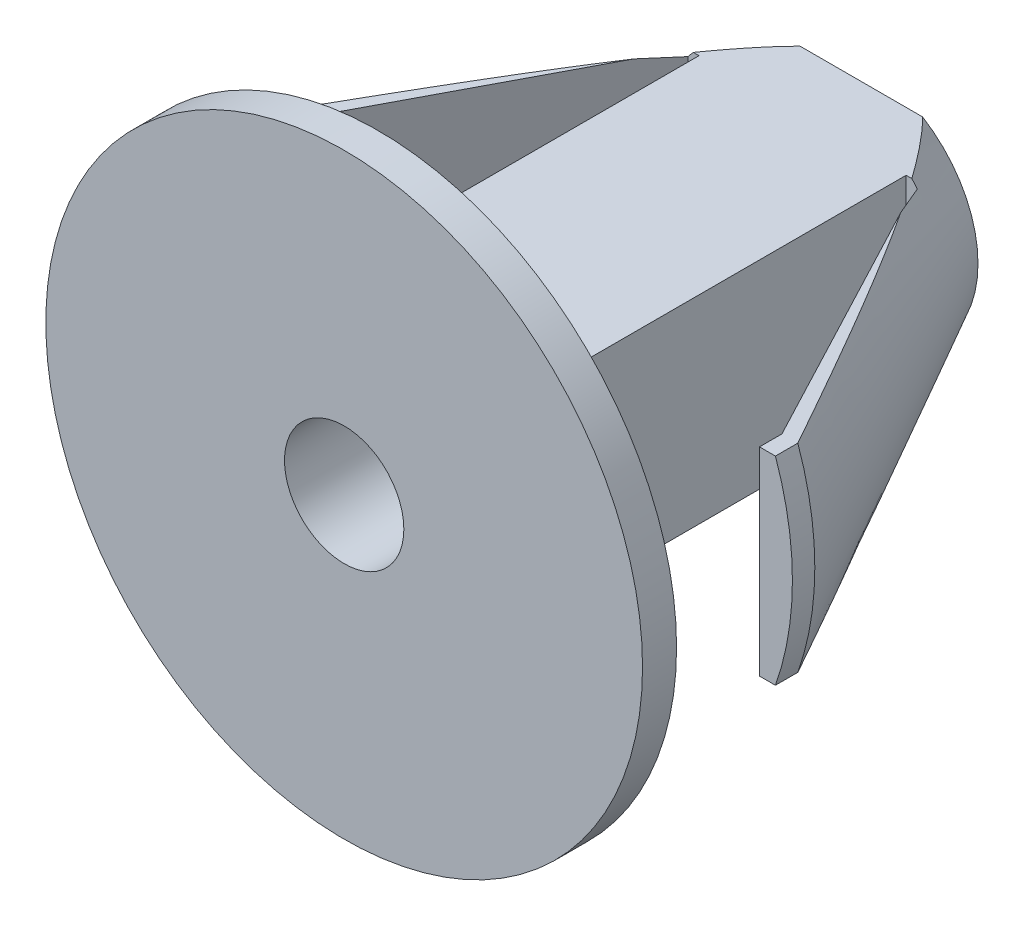
from build123d import *

# Parameters (mm, degrees)
CUT_EXTRUDE1_DEPTH      = 8.5
CUT_EXTRUDE1_DEPTH_BACK = 8.5
CUT_EXTRUDE3_DEPTH      = 8.5
CUT_EXTRUDE3_DEPTH_BACK = 8.5
CUT_EXTRUDE4_DEPTH      = 8.5
CUT_EXTRUDE4_DEPTH_BACK = 8.5
SKETCH6_R               = 1.5
CUT_EXTRUDE5_DEPTH      = 8.830238334
CUT_EXTRUDE5_DEPTH_BACK = 6.169761666
SKETCH8_R               = 2.264503928
CUT_EXTRUDE6_DEPTH      = 3


with BuildPart() as part:
    # Sketch2 → Revolve1 (revolve)
    with BuildSketch(Plane(origin=(0, 0, 0), x_dir=(1, 0, 0), z_dir=(0, 1, 0))):
        Polygon((0, 5.169761666), (-2.93214923, 5.169761666), (-7.5, -3.499678513), (-7.5, -7.830238334), (0, -7.830238334), align=None)
    revolve(axis=Axis((0, 0, 7.830238334), (0, 0, -1)))

    # Sketch3 → Cut-Extrude1 (cut, two sides)
    with BuildSketch(Plane(origin=(0, 0, 0), x_dir=(1, 0, 0), z_dir=(0, 1, 0))) as cut_extrude1_sk:
        Polygon((-7.696381126, -4.06313473), (-4.427121887, -4.06313473), (-4.427121887, -6.974818739), (-8.445586368, -6.974818739), align=None)
        Polygon((8.445586368, -6.974818739), (7.696381126, -4.06313473), (4.427121887, -4.06313473), (4.427121887, -6.974818739), align=None)
    extrude(amount=CUT_EXTRUDE1_DEPTH, mode=Mode.SUBTRACT)
    extrude(cut_extrude1_sk.sketch, amount=-CUT_EXTRUDE1_DEPTH_BACK, mode=Mode.SUBTRACT)

    # Sketch4 → Cut-Extrude3 (cut, two sides)
    with BuildSketch(Plane(origin=(0, 0, 0), x_dir=(1, 0, 0), z_dir=(0, 1, 0))) as cut_extrude3_sk:
        Polygon((-6.673039702, -4.06313473), (-6.673039702, -3.499678513), (-2.88374221, 3.692125592), (-2.603089552, 3.692125592), (-2.603089552, -4.06313473), (-2.603089552, -6.974818739), (-6.673039702, -6.974818739), align=None)
        Polygon((2.603089552, -6.974818739), (2.603089552, -4.06313473), (2.603089552, 3.692125592), (2.88374221, 3.692125592), (6.673039702, -3.499678513), (6.673039702, -4.06313473), (6.673039702, -6.974818739), align=None)
    extrude(amount=CUT_EXTRUDE3_DEPTH, mode=Mode.SUBTRACT)
    extrude(cut_extrude3_sk.sketch, amount=-CUT_EXTRUDE3_DEPTH_BACK, mode=Mode.SUBTRACT)

    # Sketch5 → Cut-Extrude4 (cut, two sides)
    with BuildSketch(Plane(origin=(0, 0, 0), x_dir=(0, 0, -1), z_dir=(1, 0, 0))) as cut_extrude4_sk:
        Polygon((-6.974818739, 2.495248244), (8.7529713, 2.495248244), (-4.227454646, 9.024441475), (-6.974818739, 9.024441475), align=None)
        Polygon((-6.974818739, -9.024441475), (-6.974818739, -2.495248244), (8.7529713, -2.495248244), (-4.227454646, -9.024441475), align=None)
    extrude(amount=CUT_EXTRUDE4_DEPTH, mode=Mode.SUBTRACT)
    extrude(cut_extrude4_sk.sketch, amount=-CUT_EXTRUDE4_DEPTH_BACK, mode=Mode.SUBTRACT)

    # Sketch6 → Cut-Extrude5 (cut, two sides)
    with BuildSketch(Plane.XY) as cut_extrude5_sk:
        Circle(SKETCH6_R)
    extrude(amount=CUT_EXTRUDE5_DEPTH, mode=Mode.SUBTRACT)
    extrude(cut_extrude5_sk.sketch, amount=-CUT_EXTRUDE5_DEPTH_BACK, mode=Mode.SUBTRACT)

    # Sketch8 → Cut-Extrude6 (cut)
    with BuildSketch(Plane(origin=(0, 0, -5.169761666), x_dir=(-1, 0, 0), z_dir=(0, 0, -1))):
        Circle(SKETCH8_R)
    extrude(amount=-CUT_EXTRUDE6_DEPTH, mode=Mode.SUBTRACT)


solid = part.part
